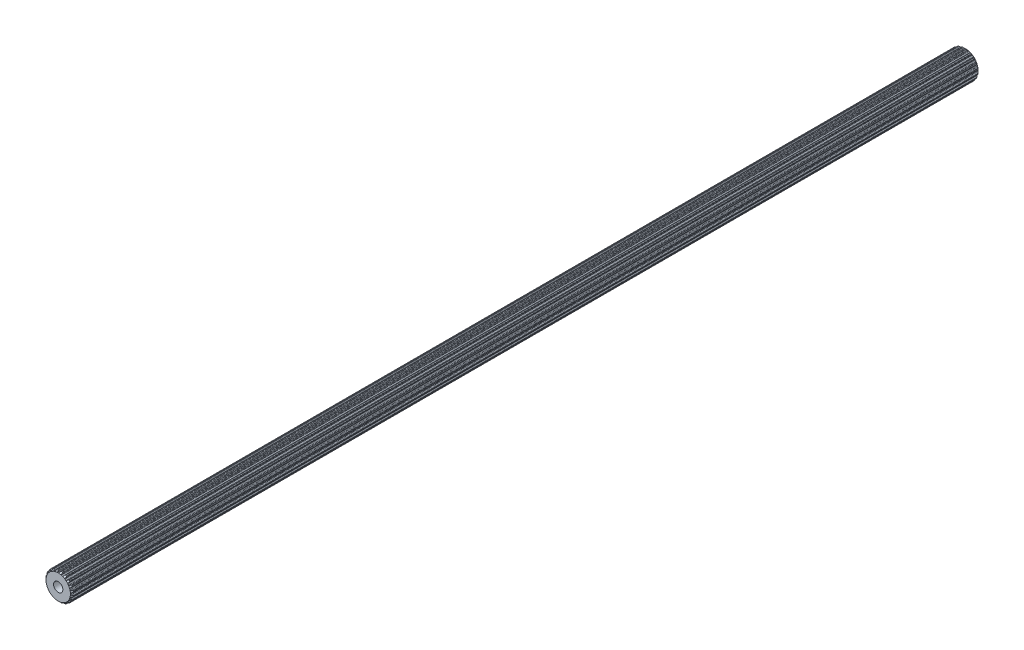
from build123d import *

# Parameters (mm, degrees)
BOSS_EXTRUDE1_DEPTH            = 110.363
CUT_EXTRUDE1_REACH             = 112.363
SKETCH6_R                      = 1.1303
CUT_EXTRUDE1_DIRECTION_2_REACH = 112.363
SKETCH7_R                      = 1.1303
BOSS_EXTRUDE2_DEPTH            = 100.838
BOSS_EXTRUDE2_DEPTH_BACK       = 100.838


with BuildPart() as part:
    # Sketch1 → Boss-Extrude1 (new body, symmetric)
    with BuildSketch(Plane.XY):
        with BuildLine():
            Line((-0.106949245, 2.969874934), (0.106949245, 2.969874934))
            ThreePointArc((0.106949245, 2.969874934), (0.196343213, 2.986924176), (0.253739238, 3.057547504))
            Line((0.253739238, 3.057547504), (0.315888147, 3.237526941))
            ThreePointArc((0.315888147, 3.237526941), (0.359032156, 3.298322911), (0.4281449, 3.326269005))
            Line((0.4281449, 3.326269005), (0.620027588, 3.2937547))
            ThreePointArc((0.620027588, 3.2937547), (0.689621142, 3.24802576), (0.718272212, 3.169836791))
            Line((0.718272212, 3.169836791), (0.724389167, 2.979527391))
            ThreePointArc((0.724389167, 2.979527391), (0.750934762, 2.9040661), (0.816027049, 2.857568043))
            Line((0.816027049, 2.857568043), (1.019456602, 2.791469774))
            ThreePointArc((1.019456602, 2.791469774), (1.109743823, 2.780060312), (1.186154496, 2.829490741))
            Line((1.186154496, 2.829490741), (1.300878326, 2.981456288))
            ThreePointArc((1.300878326, 2.981456288), (1.360697704, 3.02594446), (1.435063648, 3.031165762))
            Line((1.435063648, 3.031165762), (1.607507455, 2.940947809))
            ThreePointArc((1.607507455, 2.940947809), (1.659563839, 2.875951412), (1.662650905, 2.792735615))
            Line((1.662650905, 2.792735615), (1.609659636, 2.609850378))
            ThreePointArc((1.609659636, 2.609850378), (1.611587176, 2.529879385), (1.659124931, 2.465542482))
            Line((1.659124931, 2.465542482), (1.832172444, 2.339816104))
            ThreePointArc((1.832172444, 2.339816104), (1.914514976, 2.301064775), (2.002460687, 2.32446371))
            Line((2.002460687, 2.32446371), (2.158529469, 2.433539921))
            ThreePointArc((2.158529469, 2.433539921), (2.229168681, 2.457365482), (2.301508367, 2.439350895))
            Line((2.301508367, 2.439350895), (2.437633293, 2.300260456))
            ThreePointArc((2.437633293, 2.300260456), (2.467056864, 2.222358901), (2.444277744, 2.14226202))
            Line((2.444277744, 2.14226202), (2.337365406, 1.984703026))
            ThreePointArc((2.337365406, 1.984703026), (2.314486209, 1.908050449), (2.339816104, 1.832172444))
            Line((2.339816104, 1.832172444), (2.465542482, 1.659124931))
            ThreePointArc((2.465542482, 1.659124931), (2.531880064, 1.596824985), (2.622752074, 1.591901975))
            Line((2.622752074, 1.591901975), (2.804888709, 1.64741171))
            ThreePointArc((2.804888709, 1.64741171), (2.879433095, 1.648242449), (2.942665411, 1.608755366))
            Line((2.942665411, 1.608755366), (3.0291466, 1.434407582))
            ThreePointArc((3.0291466, 1.434407582), (3.033057175, 1.351226417), (2.986641646, 1.282088892))
            Line((2.986641646, 1.282088892), (2.836273564, 1.165279113))
            ThreePointArc((2.836273564, 1.165279113), (2.790827206, 1.099448241), (2.791469774, 1.019456602))
            Line((2.791469774, 1.019456602), (2.857568043, 0.816027049))
            ThreePointArc((2.857568043, 0.816027049), (2.901407091, 0.736276839), (2.986310214, 0.703513784))
            Line((2.986310214, 0.703513784), (3.1766859, 0.700023363))
            ThreePointArc((3.1766859, 0.700023363), (3.247838536, 0.677777961), (3.295773863, 0.620683653))
            Line((3.295773863, 0.620683653), (3.324145932, 0.4281449))
            ThreePointArc((3.324145932, 0.4281449), (3.302160717, 0.347826477), (3.236652255, 0.29641597))
            Line((3.236652255, 0.29641597), (3.057547504, 0.231789562))
            ThreePointArc((3.057547504, 0.231789562), (2.993982591, 0.183224379), (2.969874934, 0.106949245))
            Line((2.969874934, 0.106949245), (2.969874934, -0.106949245))
            ThreePointArc((2.969874934, -0.106949245), (2.986924176, -0.196343213), (3.057547504, -0.253739238))
            Line((3.057547504, -0.253739238), (3.237526941, -0.315888147))
            ThreePointArc((3.237526941, -0.315888147), (3.298322911, -0.359032156), (3.326269005, -0.4281449))
            Line((3.326269005, -0.4281449), (3.2937547, -0.620027588))
            ThreePointArc((3.2937547, -0.620027588), (3.24802576, -0.689621142), (3.169836791, -0.718272212))
            Line((3.169836791, -0.718272212), (2.979527391, -0.724389167))
            ThreePointArc((2.979527391, -0.724389167), (2.9040661, -0.750934762), (2.857568043, -0.816027049))
            Line((2.857568043, -0.816027049), (2.791469774, -1.019456602))
            ThreePointArc((2.791469774, -1.019456602), (2.780060312, -1.109743823), (2.829490741, -1.186154496))
            Line((2.829490741, -1.186154496), (2.981456288, -1.300878326))
            ThreePointArc((2.981456288, -1.300878326), (3.02594446, -1.360697704), (3.031165762, -1.435063648))
            Line((3.031165762, -1.435063648), (2.940947809, -1.607507455))
            ThreePointArc((2.940947809, -1.607507455), (2.875951412, -1.659563839), (2.792735615, -1.662650905))
            Line((2.792735615, -1.662650905), (2.609850378, -1.609659636))
            ThreePointArc((2.609850378, -1.609659636), (2.529879385, -1.611587176), (2.465542482, -1.659124931))
            Line((2.465542482, -1.659124931), (2.339816104, -1.832172444))
            ThreePointArc((2.339816104, -1.832172444), (2.301064775, -1.914514976), (2.32446371, -2.002460687))
            Line((2.32446371, -2.002460687), (2.433539921, -2.158529469))
            ThreePointArc((2.433539921, -2.158529469), (2.457365482, -2.229168681), (2.439350895, -2.301508367))
            Line((2.439350895, -2.301508367), (2.300260456, -2.437633293))
            ThreePointArc((2.300260456, -2.437633293), (2.222358901, -2.467056864), (2.14226202, -2.444277744))
            Line((2.14226202, -2.444277744), (1.984703026, -2.337365406))
            ThreePointArc((1.984703026, -2.337365406), (1.908050449, -2.314486209), (1.832172444, -2.339816104))
            Line((1.832172444, -2.339816104), (1.659124931, -2.465542482))
            ThreePointArc((1.659124931, -2.465542482), (1.596824985, -2.531880064), (1.591901975, -2.622752074))
            Line((1.591901975, -2.622752074), (1.64741171, -2.804888709))
            ThreePointArc((1.64741171, -2.804888709), (1.648242449, -2.879433095), (1.608755366, -2.942665411))
            Line((1.608755366, -2.942665411), (1.434407582, -3.0291466))
            ThreePointArc((1.434407582, -3.0291466), (1.351226417, -3.033057175), (1.282088892, -2.986641646))
            Line((1.282088892, -2.986641646), (1.165279113, -2.836273564))
            ThreePointArc((1.165279113, -2.836273564), (1.099448241, -2.790827206), (1.019456602, -2.791469774))
            Line((1.019456602, -2.791469774), (0.816027049, -2.857568043))
            ThreePointArc((0.816027049, -2.857568043), (0.736276839, -2.901407091), (0.703513784, -2.986310214))
            Line((0.703513784, -2.986310214), (0.700023363, -3.1766859))
            ThreePointArc((0.700023363, -3.1766859), (0.677777961, -3.247838536), (0.620683653, -3.295773863))
            Line((0.620683653, -3.295773863), (0.4281449, -3.324145932))
            ThreePointArc((0.4281449, -3.324145932), (0.347826477, -3.302160717), (0.29641597, -3.236652255))
            Line((0.29641597, -3.236652255), (0.231789562, -3.057547504))
            ThreePointArc((0.231789562, -3.057547504), (0.183224379, -2.993982591), (0.106949245, -2.969874934))
            Line((0.106949245, -2.969874934), (-0.106949245, -2.969874934))
            ThreePointArc((-0.106949245, -2.969874934), (-0.196343213, -2.986924176), (-0.253739238, -3.057547504))
            Line((-0.253739238, -3.057547504), (-0.315888147, -3.237526941))
            ThreePointArc((-0.315888147, -3.237526941), (-0.359032156, -3.298322911), (-0.4281449, -3.326269005))
            Line((-0.4281449, -3.326269005), (-0.620027588, -3.2937547))
            ThreePointArc((-0.620027588, -3.2937547), (-0.689621142, -3.24802576), (-0.718272212, -3.169836791))
            Line((-0.718272212, -3.169836791), (-0.724389167, -2.979527391))
            ThreePointArc((-0.724389167, -2.979527391), (-0.750934762, -2.9040661), (-0.816027049, -2.857568043))
            Line((-0.816027049, -2.857568043), (-1.019456602, -2.791469774))
            ThreePointArc((-1.019456602, -2.791469774), (-1.109743823, -2.780060312), (-1.186154496, -2.829490741))
            Line((-1.186154496, -2.829490741), (-1.300878326, -2.981456288))
            ThreePointArc((-1.300878326, -2.981456288), (-1.360697704, -3.02594446), (-1.435063648, -3.031165762))
            Line((-1.435063648, -3.031165762), (-1.607507455, -2.940947809))
            ThreePointArc((-1.607507455, -2.940947809), (-1.659563839, -2.875951412), (-1.662650905, -2.792735615))
            Line((-1.662650905, -2.792735615), (-1.609659636, -2.609850378))
            ThreePointArc((-1.609659636, -2.609850378), (-1.611587176, -2.529879385), (-1.659124931, -2.465542482))
            Line((-1.659124931, -2.465542482), (-1.832172444, -2.339816104))
            ThreePointArc((-1.832172444, -2.339816104), (-1.914514976, -2.301064775), (-2.002460687, -2.32446371))
            Line((-2.002460687, -2.32446371), (-2.158529469, -2.433539921))
            ThreePointArc((-2.158529469, -2.433539921), (-2.229168681, -2.457365482), (-2.301508367, -2.439350895))
            Line((-2.301508367, -2.439350895), (-2.437633293, -2.300260456))
            ThreePointArc((-2.437633293, -2.300260456), (-2.467056864, -2.222358901), (-2.444277744, -2.14226202))
            Line((-2.444277744, -2.14226202), (-2.337365406, -1.984703026))
            ThreePointArc((-2.337365406, -1.984703026), (-2.314486209, -1.908050449), (-2.339816104, -1.832172444))
            Line((-2.339816104, -1.832172444), (-2.465542482, -1.659124931))
            ThreePointArc((-2.465542482, -1.659124931), (-2.531880064, -1.596824985), (-2.622752074, -1.591901975))
            Line((-2.622752074, -1.591901975), (-2.804888709, -1.64741171))
            ThreePointArc((-2.804888709, -1.64741171), (-2.879433095, -1.648242449), (-2.942665411, -1.608755366))
            Line((-2.942665411, -1.608755366), (-3.0291466, -1.434407582))
            ThreePointArc((-3.0291466, -1.434407582), (-3.033057175, -1.351226417), (-2.986641646, -1.282088892))
            Line((-2.986641646, -1.282088892), (-2.836273564, -1.165279113))
            ThreePointArc((-2.836273564, -1.165279113), (-2.790827206, -1.099448241), (-2.791469774, -1.019456602))
            Line((-2.791469774, -1.019456602), (-2.857568043, -0.816027049))
            ThreePointArc((-2.857568043, -0.816027049), (-2.901407091, -0.736276839), (-2.986310214, -0.703513784))
            Line((-2.986310214, -0.703513784), (-3.1766859, -0.700023363))
            ThreePointArc((-3.1766859, -0.700023363), (-3.247838536, -0.677777961), (-3.295773863, -0.620683653))
            Line((-3.295773863, -0.620683653), (-3.324145932, -0.4281449))
            ThreePointArc((-3.324145932, -0.4281449), (-3.302160717, -0.347826477), (-3.236652255, -0.29641597))
            Line((-3.236652255, -0.29641597), (-3.057547504, -0.231789562))
            ThreePointArc((-3.057547504, -0.231789562), (-2.993982591, -0.183224379), (-2.969874934, -0.106949245))
            Line((-2.969874934, -0.106949245), (-2.969874934, 0.106949245))
            ThreePointArc((-2.969874934, 0.106949245), (-2.986924176, 0.196343213), (-3.057547504, 0.253739238))
            Line((-3.057547504, 0.253739238), (-3.237526941, 0.315888147))
            ThreePointArc((-3.237526941, 0.315888147), (-3.298322911, 0.359032156), (-3.326269005, 0.4281449))
            Line((-3.326269005, 0.4281449), (-3.2937547, 0.620027588))
            ThreePointArc((-3.2937547, 0.620027588), (-3.24802576, 0.689621142), (-3.169836791, 0.718272212))
            Line((-3.169836791, 0.718272212), (-2.979527391, 0.724389167))
            ThreePointArc((-2.979527391, 0.724389167), (-2.9040661, 0.750934762), (-2.857568043, 0.816027049))
            Line((-2.857568043, 0.816027049), (-2.791469774, 1.019456602))
            ThreePointArc((-2.791469774, 1.019456602), (-2.780060312, 1.109743823), (-2.829490741, 1.186154496))
            Line((-2.829490741, 1.186154496), (-2.981456288, 1.300878326))
            ThreePointArc((-2.981456288, 1.300878326), (-3.02594446, 1.360697704), (-3.031165762, 1.435063648))
            Line((-3.031165762, 1.435063648), (-2.940947809, 1.607507455))
            ThreePointArc((-2.940947809, 1.607507455), (-2.875951412, 1.659563839), (-2.792735615, 1.662650905))
            Line((-2.792735615, 1.662650905), (-2.609850378, 1.609659636))
            ThreePointArc((-2.609850378, 1.609659636), (-2.529879385, 1.611587176), (-2.465542482, 1.659124931))
            Line((-2.465542482, 1.659124931), (-2.339816104, 1.832172444))
            ThreePointArc((-2.339816104, 1.832172444), (-2.301064775, 1.914514976), (-2.32446371, 2.002460687))
            Line((-2.32446371, 2.002460687), (-2.433539921, 2.158529469))
            ThreePointArc((-2.433539921, 2.158529469), (-2.457365482, 2.229168681), (-2.439350895, 2.301508367))
            Line((-2.439350895, 2.301508367), (-2.300260456, 2.437633293))
            ThreePointArc((-2.300260456, 2.437633293), (-2.222358901, 2.467056864), (-2.14226202, 2.444277744))
            Line((-2.14226202, 2.444277744), (-1.984703026, 2.337365406))
            ThreePointArc((-1.984703026, 2.337365406), (-1.908050449, 2.314486209), (-1.832172444, 2.339816104))
            Line((-1.832172444, 2.339816104), (-1.659124931, 2.465542482))
            ThreePointArc((-1.659124931, 2.465542482), (-1.596824985, 2.531880064), (-1.591901975, 2.622752074))
            Line((-1.591901975, 2.622752074), (-1.64741171, 2.804888709))
            ThreePointArc((-1.64741171, 2.804888709), (-1.648242449, 2.879433095), (-1.608755366, 2.942665411))
            Line((-1.608755366, 2.942665411), (-1.434407582, 3.0291466))
            ThreePointArc((-1.434407582, 3.0291466), (-1.351226417, 3.033057175), (-1.282088892, 2.986641646))
            Line((-1.282088892, 2.986641646), (-1.165279113, 2.836273564))
            ThreePointArc((-1.165279113, 2.836273564), (-1.099448241, 2.790827206), (-1.019456602, 2.791469774))
            Line((-1.019456602, 2.791469774), (-0.816027049, 2.857568043))
            ThreePointArc((-0.816027049, 2.857568043), (-0.736276839, 2.901407091), (-0.703513784, 2.986310214))
            Line((-0.703513784, 2.986310214), (-0.700023363, 3.1766859))
            ThreePointArc((-0.700023363, 3.1766859), (-0.677777961, 3.247838536), (-0.620683653, 3.295773863))
            Line((-0.620683653, 3.295773863), (-0.4281449, 3.324145932))
            ThreePointArc((-0.4281449, 3.324145932), (-0.347826477, 3.302160717), (-0.29641597, 3.236652255))
            Line((-0.29641597, 3.236652255), (-0.231789562, 3.057547504))
            ThreePointArc((-0.231789562, 3.057547504), (-0.183224379, 2.993982591), (-0.106949245, 2.969874934))
        make_face()
    extrude(amount=BOSS_EXTRUDE1_DEPTH, both=True)

    # Sketch3 → Cut-Revolve1 (revolve, cut)
    with BuildSketch(Plane(origin=(0, 0, 0), x_dir=(0, 0, -1), z_dir=(1, 0, 0))):
        Polygon((-109.231775505, 4.101099429), (-110.363, 2.969874934), (-110.363, 4.101099429), align=None)
        Polygon((110.363, 107.076869155), (110.363, 2.969874934), (58.309502889, 55.023372045), align=None)
    revolve(axis=Axis((0, 0, 14.360793934), (0, 0, -1)), mode=Mode.SUBTRACT)

    # Cut-Extrude1: up to this face of the body (flat: up to its plane)
    cut_extrude1_end = Plane(part.part.faces().sort_by_distance((0, 0, 110.363))[0])
    # Sketch6 → Cut-Extrude1 (cut, up to the picked face)
    with BuildSketch(Plane.XY, mode=Mode.PRIVATE) as cut_extrude1_sk1:
        Circle(SKETCH6_R)
    cut_extrude1_tool1 = split(extrude(cut_extrude1_sk1.sketch, amount=CUT_EXTRUDE1_REACH, mode=Mode.PRIVATE), bisect_by=cut_extrude1_end, keep=Keep.BOTH, mode=Mode.PRIVATE)
    add(cut_extrude1_tool1.solids().sort_by_distance((0, 0, 0))[0], mode=Mode.SUBTRACT)

    # Cut-Extrude1 direction 2: up to this face of the body (flat: up to its plane)
    cut_extrude1_direction_2_end = Plane(part.part.faces().sort_by_distance((0, 0, -110.363))[0])
    # Sketch6 → Cut-Extrude1 direction 2 (cut, up to the picked face)
    with BuildSketch(Plane.XY, mode=Mode.PRIVATE) as cut_extrude1_direction_2_sk1:
        Circle(SKETCH6_R)
    cut_extrude1_direction_2_tool1 = split(extrude(cut_extrude1_direction_2_sk1.sketch, amount=-CUT_EXTRUDE1_DIRECTION_2_REACH, mode=Mode.PRIVATE), bisect_by=cut_extrude1_direction_2_end, keep=Keep.BOTH, mode=Mode.PRIVATE)
    add(cut_extrude1_direction_2_tool1.solids().sort_by_distance((0, 0, 0))[0], mode=Mode.SUBTRACT)

    # Sketch7 → Boss-Extrude2 (add, two sides)
    with BuildSketch(Plane.XY) as boss_extrude2_sk:
        Circle(SKETCH7_R)
    extrude(amount=BOSS_EXTRUDE2_DEPTH)
    extrude(boss_extrude2_sk.sketch, amount=-BOSS_EXTRUDE2_DEPTH_BACK)


solid = part.part
